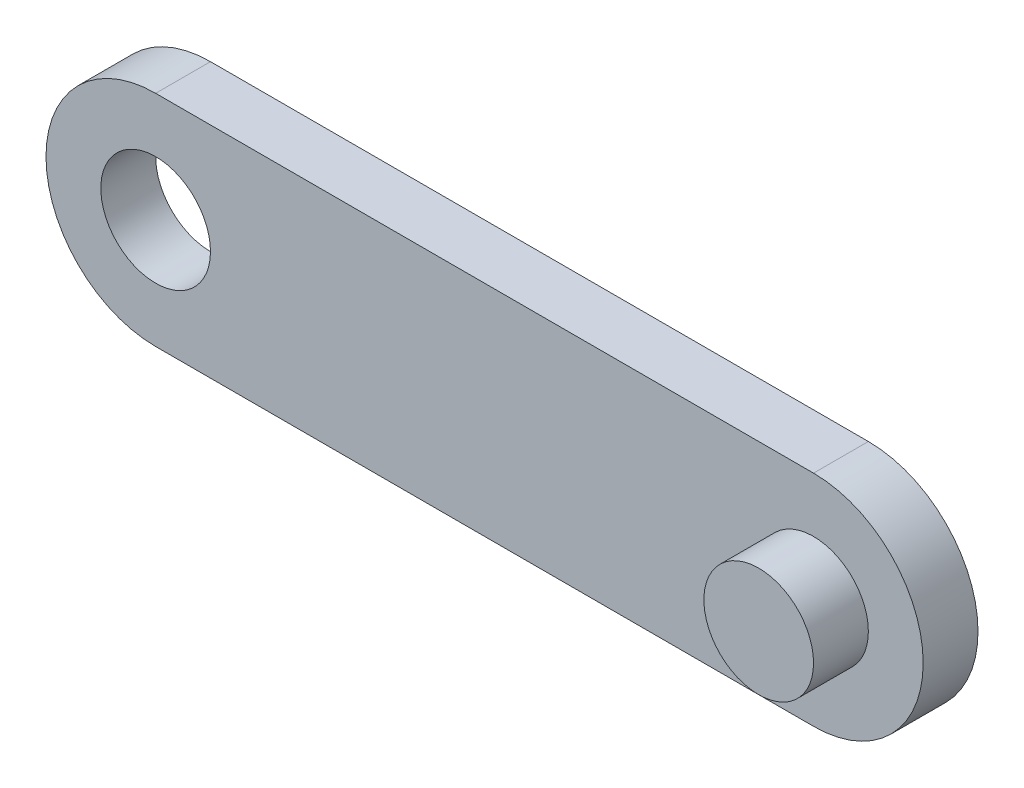
from build123d import *

# Parameters (mm, degrees)
SKETCH1_R           = 10
BOSS_EXTRUDE1_DEPTH = 10
SKETCH1_2_R         = 10
BOSS_EXTRUDE2_DEPTH = 20


with BuildPart() as part:
    # Sketch1 → Boss-Extrude1 (new body)
    with BuildSketch(Plane.XY):
        with BuildLine():
            Line((-60, 20), (60, 20))
            ThreePointArc((60, 20), (80, 0), (60, -20))
            Line((60, -20), (-60, -20))
            ThreePointArc((-60, -20), (-80, 0), (-60, 20))
        make_face()
        with Locations((-60, 0)):
            Circle(SKETCH1_R, mode=Mode.SUBTRACT)
        with Locations((60, 0)):
            Circle(SKETCH1_R, mode=Mode.SUBTRACT)
    extrude(amount=BOSS_EXTRUDE1_DEPTH)

    # Sketch1_2 → Boss-Extrude2 (add)
    with BuildSketch(Plane.XY):
        with Locations((60, 0)):
            Circle(SKETCH1_2_R)
    extrude(amount=BOSS_EXTRUDE2_DEPTH)


solid = part.part
